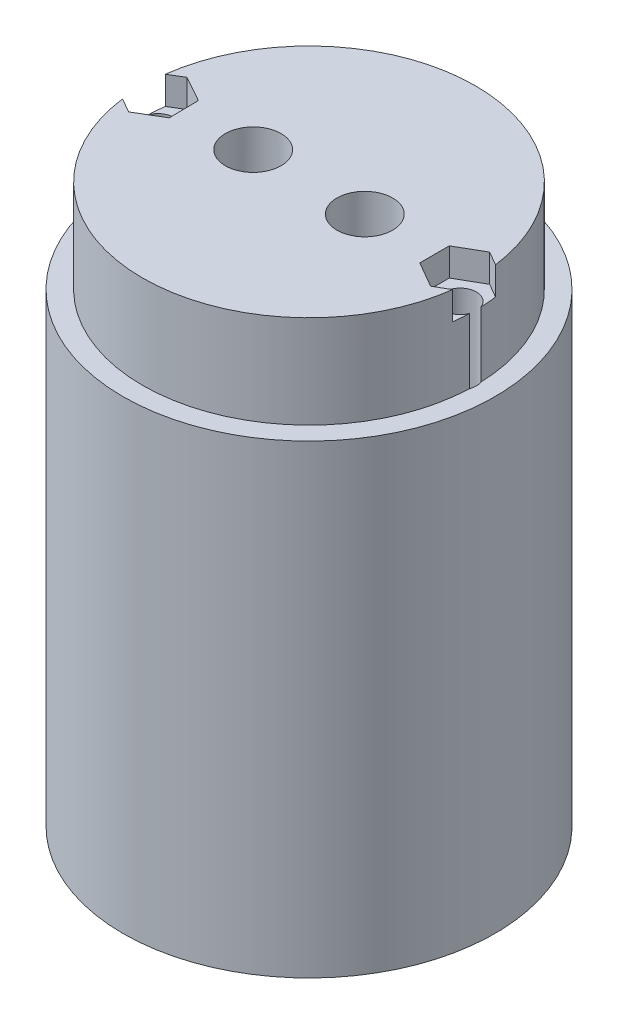
from build123d import *

# Parameters (mm, degrees)
SKETCH1_R               = 17.9
BOSS_EXTRUDE1_DEPTH     = 10
SKETCH2_R               = 20
BOSS_EXTRUDE2_DEPTH     = 40
SKETCH3_R               = 1.75
CUT_EXTRUDE1_DEPTH      = 1
CUT_EXTRUDE1_DEPTH_BACK = 119
CUT_EXTRUDE2_DEPTH      = 3
CUT_EXTRUDE4_START      = -10
SKETCH5_R               = 12
CUT_EXTRUDE4_DEPTH      = 43
FILLET1_R               = 10
SKETCH6_R               = 20
SKETCH6_R_2             = 18
BOSS_EXTRUDE3_DEPTH     = 10
SKETCH7_R               = 13
CUT_EXTRUDE5_DEPTH      = 40
FILLET2_R               = 10
SKETCH8_R               = 3
CUT_EXTRUDE6_DEPTH      = 11
CUT_EXTRUDE6_DEPTH_BACK = 51
SKETCH10_R              = 14
CUT_EXTRUDE7_DEPTH      = 15


with BuildPart() as part:
    # Sketch1 → Boss-Extrude1 (new body)
    with BuildSketch(Plane(origin=(0, 13.694359, 0), x_dir=(-1, 0, 0), z_dir=(0, -1, 0))):
        with Locations((-0.536003, -73.600817)):
            Circle(SKETCH1_R)
    extrude(amount=BOSS_EXTRUDE1_DEPTH)

    # Sketch2 → Boss-Extrude2 (add)
    with BuildSketch(Plane(origin=(0, 3.694359, 0), x_dir=(-1, 0, 0), z_dir=(0, -1, 0))):
        with Locations((-0.536003, -73.600817)):
            Circle(SKETCH2_R)
    extrude(amount=BOSS_EXTRUDE2_DEPTH)

    # Sketch3 → Cut-Extrude1 (cut, two sides)
    with BuildSketch(Plane(origin=(0, 81.694359, 0), x_dir=(1, 0, 0), z_dir=(0, 1, 0))) as cut_extrude1_sk:
        with Locations((-15.713997, -73.600817)):
            Circle(SKETCH3_R)
        with Locations((16.786003, -73.600817)):
            Circle(SKETCH3_R)
    extrude(amount=CUT_EXTRUDE1_DEPTH, mode=Mode.SUBTRACT)
    extrude(cut_extrude1_sk.sketch, amount=-CUT_EXTRUDE1_DEPTH_BACK, mode=Mode.SUBTRACT)

    # Sketch4 → Cut-Extrude2 (cut)
    with BuildSketch(Plane(origin=(0, 13.694359, 0), x_dir=(1, 0, 0), z_dir=(0, 1, 0))):
        Polygon((-15.759938, -70.425723), (-18.48668, -72.053056), (-18.440739, -75.22815), (-15.668056, -76.775911), (-12.941314, -75.148578), (-12.987255, -71.973484), align=None)
        Polygon((16.786003, -70.42539), (14.036003, -72.013104), (14.036003, -75.18853), (16.786003, -76.776243), (19.536003, -75.18853), (19.536003, -72.013104), align=None)
    extrude(amount=-CUT_EXTRUDE2_DEPTH, mode=Mode.SUBTRACT)

    # Sketch5 → Cut-Extrude4 (cut)
    with BuildSketch(Plane(origin=(0, 13.694359, 0), x_dir=(1, 0, 0), z_dir=(0, 1, 0)).offset(CUT_EXTRUDE4_START)):
        with Locations((0.536003, -73.600817)):
            Circle(SKETCH5_R)
    extrude(amount=-CUT_EXTRUDE4_DEPTH, mode=Mode.SUBTRACT)

    # Fillet1
    fillet1_edges = [part.edges().sort_by_distance(p)[0] for p in [
        (-11.463997, 3.694359, 73.600817),
    ]]
    fillet(fillet1_edges, radius=FILLET1_R)

    # Sketch6 → Boss-Extrude3 (add)
    with BuildSketch(Plane.XZ.offset(36.305641)):
        with Locations((0.536003, 73.600817)):
            Circle(SKETCH6_R)
        with Locations((0.536003, 73.600817)):
            Circle(SKETCH6_R_2, mode=Mode.SUBTRACT)
    extrude(amount=BOSS_EXTRUDE3_DEPTH)

    # Sketch7 → Cut-Extrude5 (cut)
    with BuildSketch(Plane(origin=(0, -36.305641, 0), x_dir=(-1, 0, 0), z_dir=(0, -1, 0))):
        with Locations((-0.536003, -73.600817)):
            Circle(SKETCH7_R)
    extrude(amount=-CUT_EXTRUDE5_DEPTH, mode=Mode.SUBTRACT)

    # Fillet2
    fillet2_edges = [part.edges().sort_by_distance(p)[0] for p in [
        (13.536003, 3.694359, 73.600817),
    ]]
    fillet(fillet2_edges, radius=FILLET2_R)

    # Sketch8 → Cut-Extrude6 (cut, two sides)
    with BuildSketch(Plane(origin=(0, -36.305641, 0), x_dir=(-1, 0, 0), z_dir=(0, -1, 0))) as cut_extrude6_sk:
        with Locations((5.463997, -73.600817)):
            Circle(SKETCH8_R)
        with Locations((-6.536003, -73.600817)):
            Circle(SKETCH8_R)
    extrude(amount=CUT_EXTRUDE6_DEPTH, mode=Mode.SUBTRACT)
    extrude(cut_extrude6_sk.sketch, amount=-CUT_EXTRUDE6_DEPTH_BACK, mode=Mode.SUBTRACT)

    # Sketch10 → Cut-Extrude7 (cut)
    with BuildSketch(Plane(origin=(0, -36.305641, 0), x_dir=(-1, 0, 0), z_dir=(0, -1, 0))):
        with Locations((-0.536003, -73.600817)):
            Circle(SKETCH10_R)
    extrude(amount=-CUT_EXTRUDE7_DEPTH, mode=Mode.SUBTRACT)


solid = part.part
